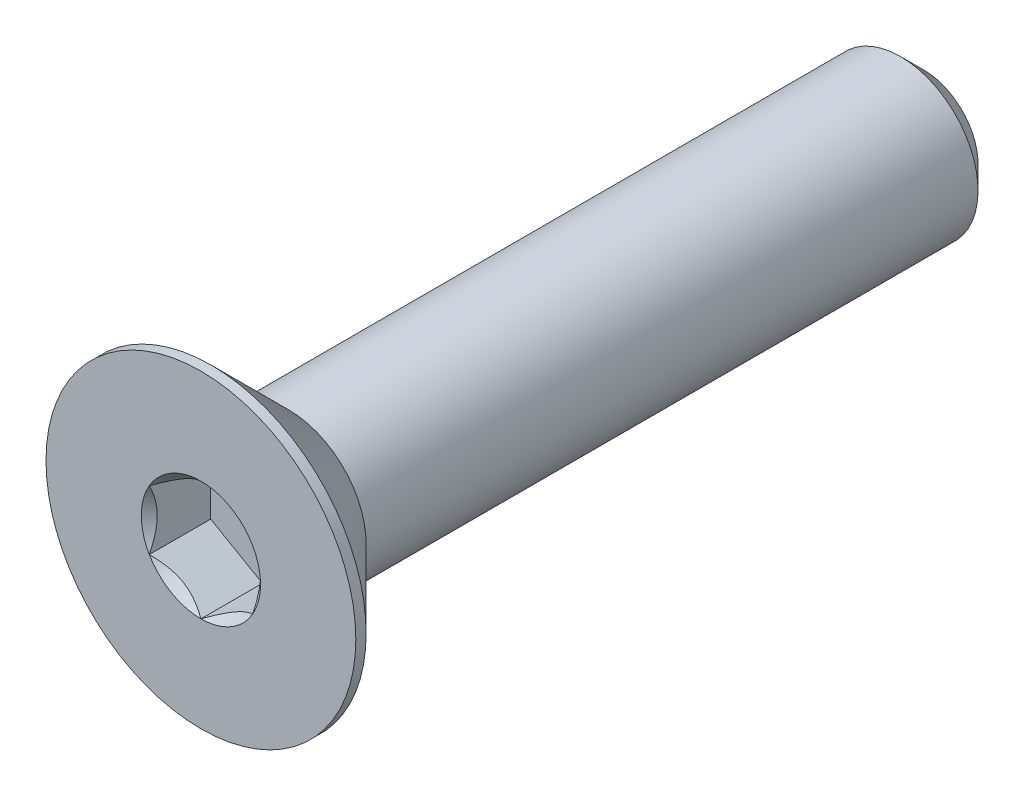
from build123d import *

# Parameters (mm, degrees)
SKETCH3_W          = 14
SKETCH3_H          = 1.5
CHAMFER1_SIZE      = 0.45
CUT_EXTRUDE1_DEPTH = 1.19


with BuildPart() as part:
    # Sketch3 → Revolve1 (revolve)
    with BuildSketch(Plane(origin=(0, 0, 0), x_dir=(0, 0, -1), z_dir=(1, 0, 0))):
        with Locations((0, 0.75)):
            Rectangle(SKETCH3_W, SKETCH3_H)
    revolve(axis=Axis((0, 0, -7), (0, 0, 1)))

    # Chamfer1
    chamfer1_edges = [part.edges().sort_by_distance(p)[0] for p in [
        (0, -1.5, -7),
    ]]
    chamfer(chamfer1_edges, length=CHAMFER1_SIZE)

    # Sketch6 → Revolve2 (revolve)
    with BuildSketch(Plane(origin=(0, 0, 0), x_dir=(0, 0, -1), z_dir=(1, 0, 0))):
        Polygon((-7, 3), (-6.8, 3), (-5.3, 1.5), (-5.3, 0), (-7, 0), align=None)
    revolve(axis=Axis((0, 0, -7), (0, 0, 1)))

    # Sketch8 → Cut-Extrude1 (cut)
    with BuildSketch(Plane.XY.offset(7)):
        Polygon((0, 1.154700538), (-1, 0.577350269), (-1, -0.577350269), (0, -1.154700538), (1, -0.577350269), (1, 0.577350269), align=None)
    extrude(amount=-CUT_EXTRUDE1_DEPTH, mode=Mode.SUBTRACT)

    # Cut-Extrude2 cone 1 section (through the dimple's axis) → Cut-Extrude2 (revolve, cut)
    with BuildSketch(Plane(origin=(0, 0, 7), x_dir=(0, -1, 0), z_dir=(1, 0, 0))):
        Polygon((0, 0), (1.154700538, 0), (0, 1.154700538), align=None)
    revolve(axis=Axis((0, 0, 7), (0, 0, -1)), mode=Mode.SUBTRACT)


solid = part.part
